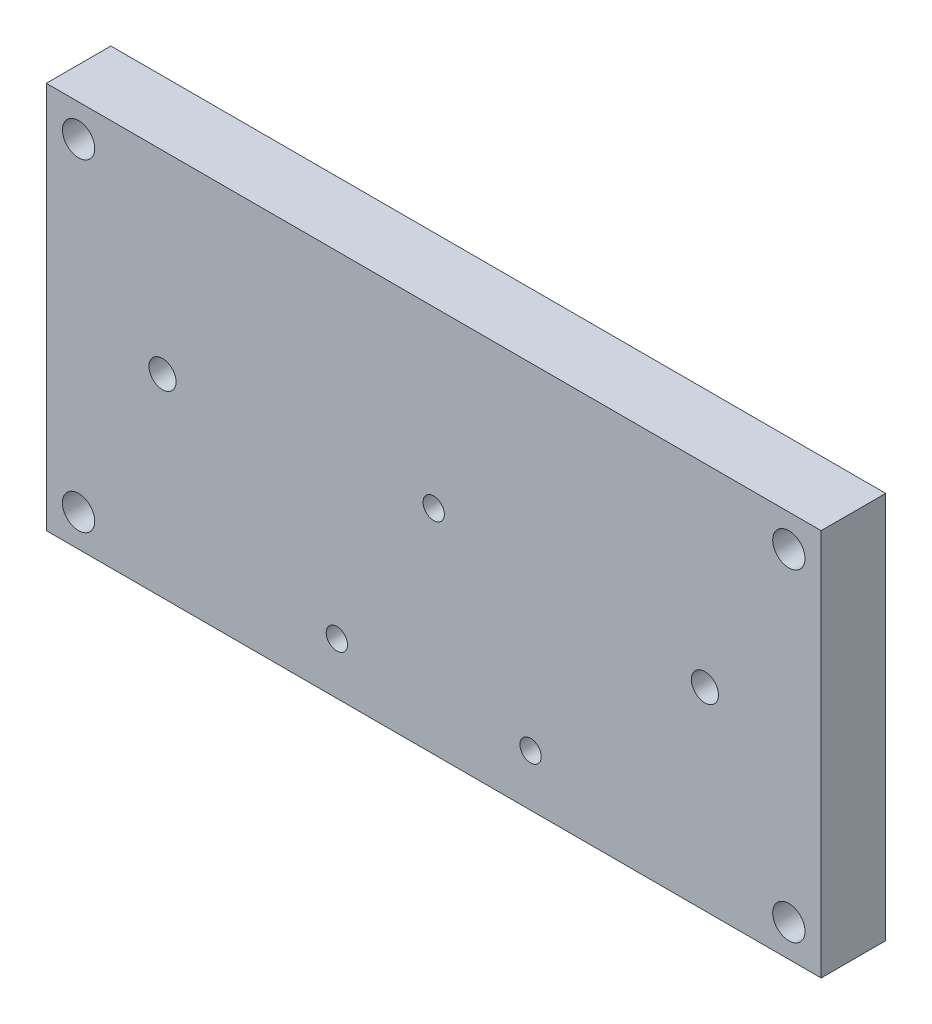
from build123d import *

# Parameters (mm, degrees)
SKIZZE1_W                       = 120
SKIZZE1_H                       = 60
AUFSATZ_LINEAR_AUSTRAGEN1_DEPTH = 10
M6_GEWINDEBOHRUNG1_D            = 5
M5_GEWINDEBOHRUNG1_D            = 4.2
M4_GEWINDEBOHRUNG1_D            = 3.3


with BuildPart() as part:
    # Skizze1 → Aufsatz-Linear austragen1 (new body)
    with BuildSketch(Plane.XY):
        Rectangle(SKIZZE1_W, SKIZZE1_H)
    extrude(amount=AUFSATZ_LINEAR_AUSTRAGEN1_DEPTH)

    # M6 Gewindebohrung1 (through all)
    with Locations(Plane.XY.offset(10)):
        with Locations((-55, -25), (-55, 25), (55, 25), (55, -25)):
            Hole(M6_GEWINDEBOHRUNG1_D / 2)

    # M5 Gewindebohrung1 (through all)
    with Locations(Plane.XY.offset(10)):
        with Locations((-42, 0), (42, 0)):
            Hole(M5_GEWINDEBOHRUNG1_D / 2)

    # M4 Gewindebohrung1 (through all)
    with Locations(Plane.XY.offset(10)):
        with Locations((0, 3), (-15, -22), (15, -22)):
            Hole(M4_GEWINDEBOHRUNG1_D / 2)


solid = part.part
